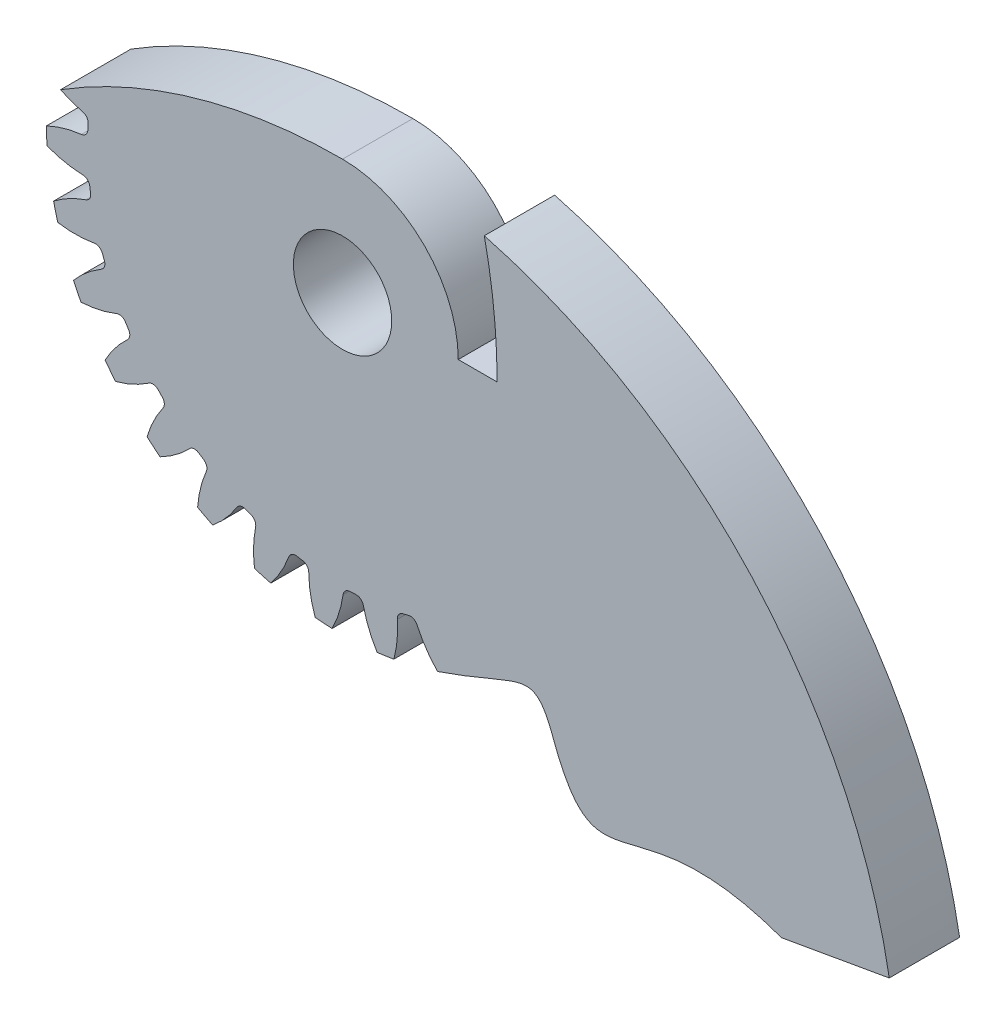
from build123d import *

# Parameters (mm, degrees)
SKETCH3_R           = 40.64
GEARBODY_DEPTH      = 9.652
TOOTHCUT_DEPTH      = 10.652
CIRPATTERN1_COUNT   = 30
BOREDIA_R           = 6.746875
BORE_DEPTH          = 12700
CUT_EXTRUDE1_DEPTH  = 10.652
BOSS_EXTRUDE1_DEPTH = 9.652
CUT_EXTRUDE2_DEPTH  = 10.6520001


with BuildPart() as part:
    # Sketch3 → gearBody (new body)
    with BuildSketch(Plane.XY):
        Circle(SKETCH3_R)
    extrude(amount=GEARBODY_DEPTH)

    # Sketch2 → toothCut (cut, through all)
    with BuildSketch(Plane.XY):
        with BuildLine():
            ThreePointArc((34.901466352, -2.640387833), (34.929801576, -2.234493965), (34.953416534, -1.828298136))
            ThreePointArc((34.953416534, -1.828298136), (35.218972856, -1.205360668), (35.823821616, -0.900845929))
            ThreePointArc((35.823821616, -0.900845929), (41.902420255, 1.180053047), (46.567899911, 5.597382731))
            ThreePointArc((46.567899911, 5.597382731), (46.807414621, -2.994316622), (45.4750933, -11.485464069))
            ThreePointArc((45.4750933, -11.485464069), (41.410501506, -6.509663078), (35.646600115, -3.671187658))
            ThreePointArc((35.646600115, -3.671187658), (35.08548304, -3.292084932), (34.901466352, -2.640387833))
        make_face()
    toothcut = extrude(amount=TOOTHCUT_DEPTH, mode=Mode.SUBTRACT)

    # CirPattern1: toothCut ×30 about axis
    cirpattern1_axis = Axis((0, 0, 0), (0, 0, 1))
    for i in range(1, CIRPATTERN1_COUNT):
        add(toothcut.rotate(cirpattern1_axis, i * 360 / CIRPATTERN1_COUNT), mode=Mode.SUBTRACT)

    # boreDia → bore (cut, symmetric)
    with BuildSketch(Plane.XY):
        Circle(BOREDIA_R)
    extrude(amount=BORE_DEPTH, both=True, mode=Mode.SUBTRACT)

    # Sketch4 → Cut-Extrude1 (cut, through all)
    with BuildSketch(Plane.XY.offset(9.652)):
        with BuildLine():
            ThreePointArc((-41.719518102, 6.584225456), (0, 19.0246), (41.719518102, 6.584225456))
            ThreePointArc((41.719518102, 6.584225456), (0, 42.235887767), (-41.719518102, 6.584225456))
        make_face()
    extrude(amount=-CUT_EXTRUDE1_DEPTH, mode=Mode.SUBTRACT)

    # Sketch5 → Boss-Extrude1 (add)
    with BuildSketch(Plane.XY.offset(9.652)):
        with BuildLine():
            Line((0, 19.0246), (21.516273518, 3.717628196))
            Line((21.516273518, 3.717628196), (8.960832095, -26.928019276))
            Line((8.960832095, -26.928019276), (13.028048789, -38.495188592))
            add(Edge.make_bspline(
                [(13.028048789, -38.495188592), (20.557027875, -35.948016391), (26.651698234, -31.725988422), (34.665054684, -56.754549328), (39.534520581, -39.016908481), (60.232048781, -46.529464697)],
                knots=[0, 0, 0, 0, 0.11851508, 0.21851508, 1, 1, 1, 1], degree=3))
            Line((60.232048781, -46.529464697), (75.017336663, -43.922419525))
            ThreePointArc((75.017336663, -43.922419525), (48.964089053, 1.203129037), (0, 19.0246))
        make_face()
    extrude(amount=-BOSS_EXTRUDE1_DEPTH)

    # Sketch6 → Cut-Extrude2 (cut, through all)
    with BuildSketch(Plane.XY.offset(9.652)):
        with BuildLine():
            Line((-41.299293436, 3.074737332), (-42.33973186, 6.17390379))
            ThreePointArc((-42.33973186, 6.17390379), (-12.554296612, 17.982944317), (19.452320435, 16.499011635))
            ThreePointArc((19.452320435, 16.499011635), (20.76859248, 8.296133256), (21.209, 0))
            Line((21.209, 0), (15.875, 0))
            ThreePointArc((15.875, 0), (11.225320151, 11.225320151), (0, 15.875))
            ThreePointArc((0, 15.875), (-21.618732402, 12.601566537), (-41.299293436, 3.074737332))
        make_face()
    extrude(amount=-CUT_EXTRUDE2_DEPTH, mode=Mode.SUBTRACT)


solid = part.part
